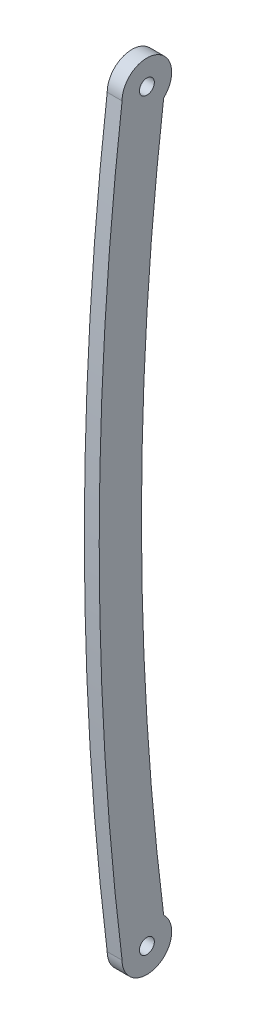
from build123d import *

# Parameters (mm, degrees)
CROQUIS1_R              = 1.5
SALIENTE_EXTRUIR1_DEPTH = 3


with BuildPart() as part:
    # Croquis1 → Saliente-Extruir1 (new body)
    with BuildSketch(Plane(origin=(0, 0, 0), x_dir=(0, 0, -1), z_dir=(1, 0, 0))):
        with BuildLine():
            ThreePointArc((-5, 0), (2.011533945, -4.57752457), (3.381492475, 3.683138423))
            ThreePointArc((3.381492475, 3.683138423), (-1.096196525, 75), (3.381492475, 146.316861577))
            ThreePointArc((3.381492475, 146.316861577), (2.011533945, 154.57752457), (-5, 150))
            ThreePointArc((-5, 150), (-9.607489913, 75), (-5, 0))
        make_face()
        with Locations((0, 150)):
            Circle(CROQUIS1_R, mode=Mode.SUBTRACT)
        Circle(CROQUIS1_R, mode=Mode.SUBTRACT)
    extrude(amount=SALIENTE_EXTRUIR1_DEPTH)


solid = part.part
